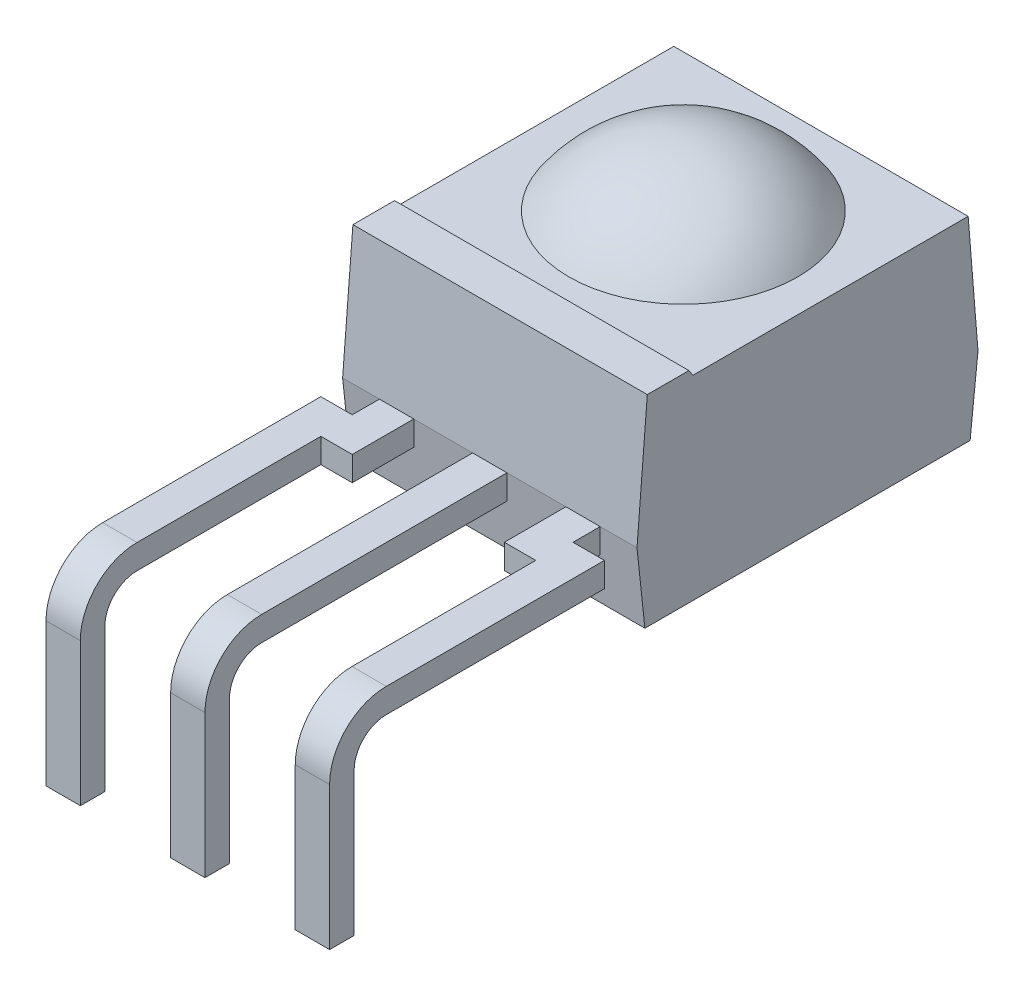
from build123d import *

# Parameters (mm, degrees)
SKETCH1_W             = 6
SKETCH1_H             = 6.95
BOSS_EXTRUDE1_DEPTH   = 4.1
CUT_EXTRUDE2_DEPTH    = 10
SKETCH6_W             = 0.7
SKETCH6_H             = 5
BOSS_EXTRUDE2_DEPTH   = 0.5
BOSS_EXTRUDE2_2_DEPTH = 0.5
BOSS_EXTRUDE2_3_DEPTH = 0.5
SKETCH8_W             = 0.7
SKETCH8_H             = 0.5
LPATTERN1_COUNT       = 2
LPATTERN1_PITCH       = 2.54
LPATTERN2_COUNT       = 2
LPATTERN2_PITCH       = 2.54


with BuildPart() as part:
    # Sketch1 → Boss-Extrude1 (new body)
    with BuildSketch(Plane(origin=(0, 0, 0), x_dir=(1, 0, 0), z_dir=(0, 1, 0))):
        Rectangle(SKETCH1_W, SKETCH1_H)
    extrude(amount=BOSS_EXTRUDE1_DEPTH)

    # Sketch2 → Cut-Extrude2 (cut)
    with BuildSketch(Plane.ZY.offset(3)):
        Polygon((-3.475, 1.5), (-3.274875222, 3.976607761), (2.335282133, 3.976607761), (2.548204916, 4.299426173), (-3.248789555, 4.299426173), (-4.086743732, 4.299426173), (-4.086743732, -0.611534783), (-3.248789555, -0.611534783), align=None)
        Polygon((3.248789555, -0.611534783), (3.475, 1.5), (3.248789555, 4.299426173), (4.086743732, 4.299426173), (4.086743732, -0.611534783), align=None)
    extrude(amount=-CUT_EXTRUDE2_DEPTH, mode=Mode.SUBTRACT)

    # Sketch5 → Revolve2 (revolve)
    with BuildSketch(Plane(origin=(0, 0, 0), x_dir=(0, 0, -1), z_dir=(1, 0, 0))):
        with BuildLine():
            Line((0.469796544, 5.21616514), (0.469796544, 3.976607761))
            Line((0.469796544, 3.976607761), (2.803412544, 3.976607761))
            ThreePointArc((2.803412544, 3.976607761), (1.790995444, 4.887045907), (0.469796544, 5.21616514))
        make_face()
    revolve(axis=Axis((0, 3.976607761, -0.469796544), (0, -1, 0)))


with BuildPart() as body_2:
    # Sketch6 → Boss-Extrude2 (new body)
    with BuildSketch(Plane(origin=(0, 1.5, 0), x_dir=(1, 0, 0), z_dir=(0, 1, 0))):
        with Locations((0, -5.975)):
            Rectangle(SKETCH6_W, SKETCH6_H)
    extrude(amount=-BOSS_EXTRUDE2_DEPTH)

    # Sweep1: sweep along a path in Sketch7
    with BuildLine(Plane(origin=(0, 0, 0), x_dir=(0, 0, -1), z_dir=(1, 0, 0))) as sweep1_path:
        Line((-9.380387544, -2.569590895), (-9.380387544, 0.344612456))
        ThreePointArc((-9.380387544, 0.344612456), (-9.115205672, 0.984818128), (-8.475, 1.25))
    # Sketch8 → Sweep1 (sweep)
    with BuildSketch(Plane.XY.offset(8.475)):
        with Locations((0, 1.25)):
            Rectangle(SKETCH8_W, SKETCH8_H)
    sweep1 = sweep(path=sweep1_path.line)


with BuildPart() as body_3:
    # Sketch6 → Boss-Extrude2 2 (new body)
    with BuildSketch(Plane(origin=(0, 1.5, 0), x_dir=(1, 0, 0), z_dir=(0, 1, 0))):
        Polygon((-1.55, -3.475), (-1.55, -4.72854454), (-2.19, -4.72854454), (-2.19, -8.475), (-2.89, -8.475), (-2.89, -4.02854454), (-2.25, -4.02854454), (-2.25, -3.475), align=None)
    extrude(amount=-BOSS_EXTRUDE2_2_DEPTH)

    # LPattern2: Sweep1 ×2
    with Locations(*[(-i * LPATTERN2_PITCH, 0, 0) for i in range(1, LPATTERN2_COUNT)]):
        add(sweep1)


with BuildPart() as body_4:
    # Sketch6 → Boss-Extrude2 3 (new body)
    with BuildSketch(Plane(origin=(0, 1.5, 0), x_dir=(1, 0, 0), z_dir=(0, 1, 0))):
        Polygon((2.89, -4.02854454), (2.25, -4.02854454), (2.25, -3.475), (1.55, -3.475), (1.55, -4.72854454), (2.19, -4.72854454), (2.19, -8.475), (2.89, -8.475), align=None)
    extrude(amount=-BOSS_EXTRUDE2_3_DEPTH)

    # LPattern1: Sweep1 ×2
    with Locations(*[(i * LPATTERN1_PITCH, 0, 0) for i in range(1, LPATTERN1_COUNT)]):
        add(sweep1)


solid = Compound([part.part, body_2.part, body_3.part, body_4.part])
